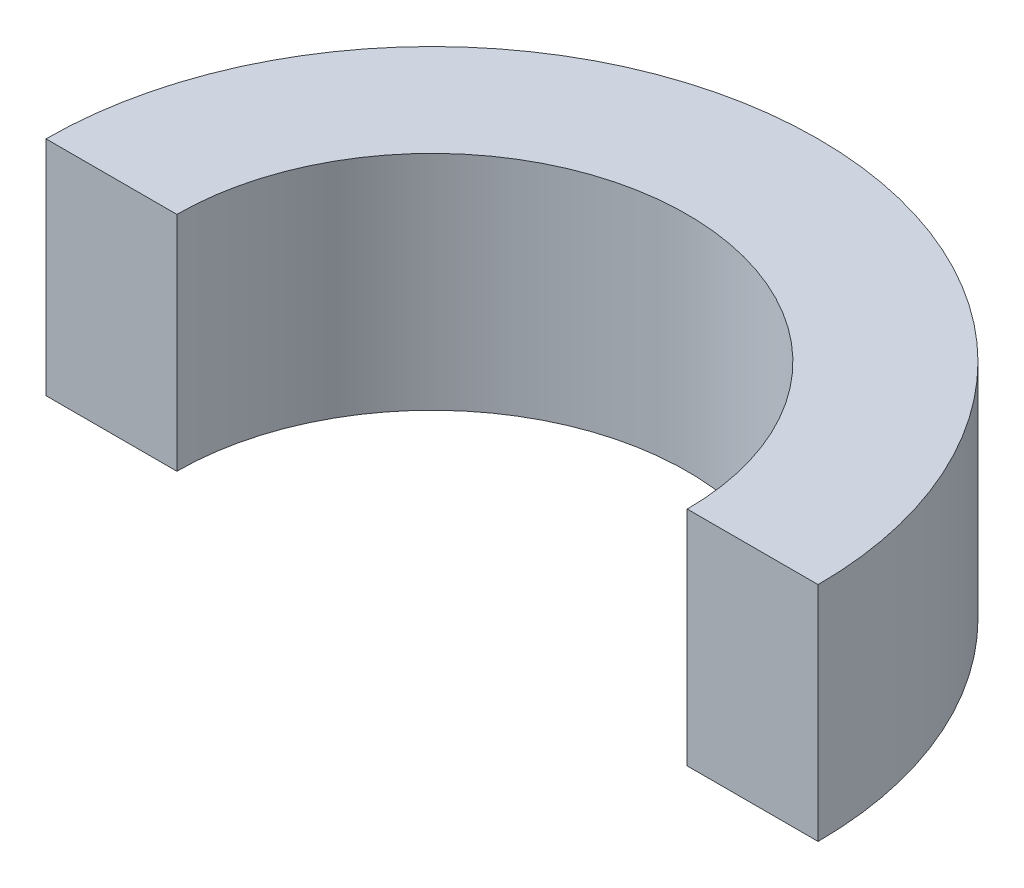
from build123d import *

# Parameters (mm, degrees)
BOSS_EXTRUDE1_DEPTH = 17


with BuildPart() as part:
    # Sketch2 → Boss-Extrude1 (new body)
    with BuildSketch(Plane(origin=(0, 0, 0), x_dir=(1, 0, 0), z_dir=(0, 1, 0))):
        with BuildLine():
            ThreePointArc((-29.5, 0), (0, 29.5), (29.5, 0))
            Line((29.5, 0), (19.5, 0))
            ThreePointArc((19.5, 0), (0, 19.5), (-19.5, 0))
            Line((-19.5, 0), (-29.5, 0))
        make_face()
    extrude(amount=BOSS_EXTRUDE1_DEPTH)


solid = part.part
